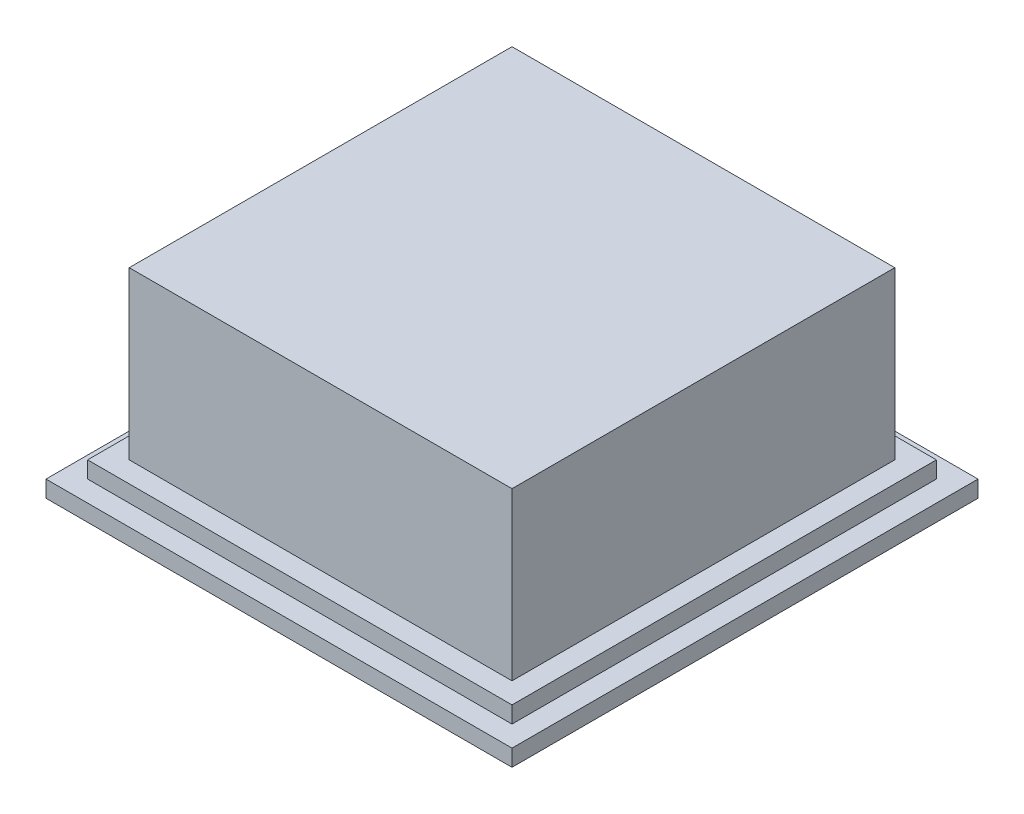
from build123d import *

# Parameters (mm, degrees)
SKETCH1_W           = 28
SKETCH1_H           = 28
BOSS_EXTRUDE1_DEPTH = 1
SKETCH2_W           = 25.5
SKETCH2_H           = 25.5
BOSS_EXTRUDE2_DEPTH = 1
SKETCH3_W           = 23
SKETCH3_H           = 23
BOSS_EXTRUDE3_DEPTH = 10


with BuildPart() as part:
    # Sketch1 → Boss-Extrude1 (new body)
    with BuildSketch(Plane(origin=(0, 0, 0), x_dir=(1, 0, 0), z_dir=(0, 1, 0))):
        Rectangle(SKETCH1_W, SKETCH1_H)
    extrude(amount=BOSS_EXTRUDE1_DEPTH)

    # Sketch2 → Boss-Extrude2 (add)
    with BuildSketch(Plane(origin=(0, 1, 0), x_dir=(1, 0, 0), z_dir=(0, 1, 0))):
        Rectangle(SKETCH2_W, SKETCH2_H)
    extrude(amount=BOSS_EXTRUDE2_DEPTH)

    # Sketch3 → Boss-Extrude3 (add)
    with BuildSketch(Plane(origin=(0, 2, 0), x_dir=(1, 0, 0), z_dir=(0, 1, 0))):
        Rectangle(SKETCH3_W, SKETCH3_H)
    extrude(amount=BOSS_EXTRUDE3_DEPTH)


solid = part.part
